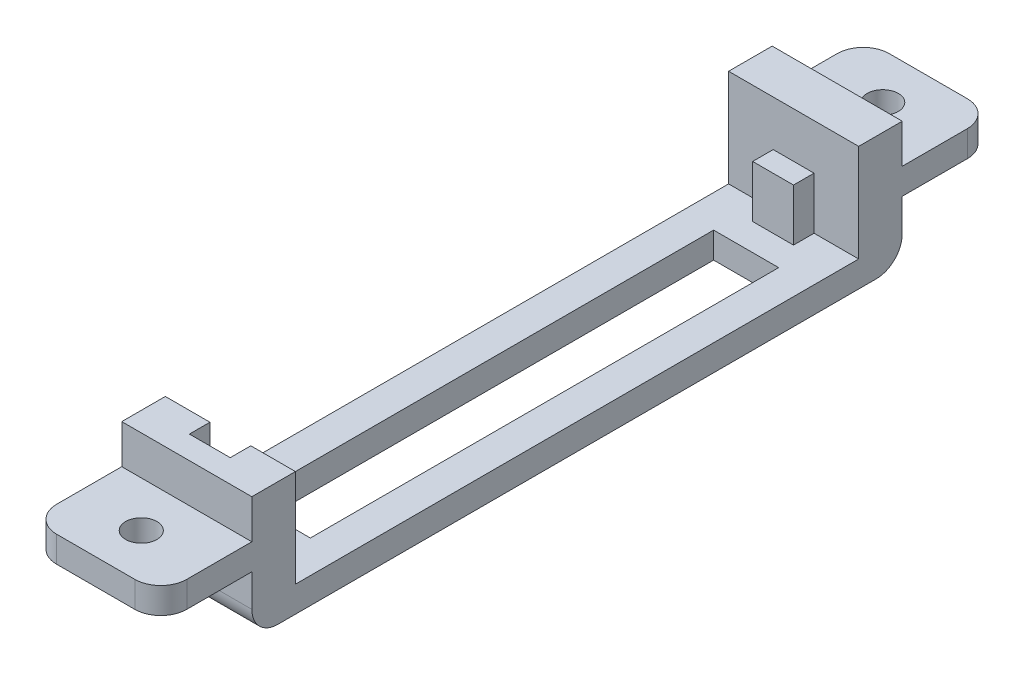
from build123d import *

# Parameters (mm, degrees)
SKETCH1_W           = 12.7
SKETCH1_H           = 63.5
SKETCH1_W_2         = 6.35
SKETCH1_H_2         = 45.72
BOSS_EXTRUDE1_DEPTH = 2.54
BOSS_EXTRUDE2_DEPTH = 9.525
SKETCH5_W           = 3.9878
SKETCH5_H           = 2.0066
CUT_EXTRUDE1_DEPTH  = 4.445
SKETCH7_W           = 12.7
SKETCH7_H           = 8.89
SKETCH7_R           = 1.524
BOSS_EXTRUDE4_DEPTH = 2.54
FILLET1_R           = 2.54


with BuildPart() as part:
    # Sketch1 → Boss-Extrude1 (new body)
    with BuildSketch(Plane(origin=(0, 0, 0), x_dir=(1, 0, 0), z_dir=(0, 1, 0))):
        Rectangle(SKETCH1_W, SKETCH1_H)
        Rectangle(SKETCH1_W_2, SKETCH1_H_2, mode=Mode.SUBTRACT)
    extrude(amount=BOSS_EXTRUDE1_DEPTH)

    # Sketch2 → Boss-Extrude2 (add)
    with BuildSketch(Plane(origin=(0, 2.54, 0), x_dir=(1, 0, 0), z_dir=(0, 1, 0))):
        Polygon((-6.35, 31.75), (6.35, 31.75), (6.35, 27.4955), (1.9939, 27.4955), (1.9939, 25.4889), (-1.9939, 25.4889), (-1.9939, 27.4955), (-6.35, 27.4955), align=None)
        Polygon((-6.35, -27.4955), (-6.35, -31.75), (6.35, -31.75), (6.35, -27.4955), (1.9939, -27.4955), (1.9939, -29.5021), (-1.9939, -29.5021), (-1.9939, -27.4955), align=None)
    extrude(amount=BOSS_EXTRUDE2_DEPTH)

    # Sketch5 → Cut-Extrude1 (cut)
    with BuildSketch(Plane(origin=(0, 12.065, 0), x_dir=(1, 0, 0), z_dir=(0, 1, 0))):
        with Locations((0, 26.4922)):
            Rectangle(SKETCH5_W, SKETCH5_H)
    extrude(amount=-CUT_EXTRUDE1_DEPTH, mode=Mode.SUBTRACT)

    # Sketch7 → Boss-Extrude4 (add)
    with BuildSketch(Plane(origin=(0, 8.255, 0), x_dir=(1, 0, 0), z_dir=(0, 1, 0))):
        with Locations((0, 36.195)):
            Rectangle(SKETCH7_W, SKETCH7_H)
        with Locations((0, 36.195)):
            Circle(SKETCH7_R, mode=Mode.SUBTRACT)
        with Locations((0, -36.195)):
            Rectangle(SKETCH7_W, SKETCH7_H)
        with Locations((0, -36.195)):
            Circle(SKETCH7_R, mode=Mode.SUBTRACT)
    extrude(amount=-BOSS_EXTRUDE4_DEPTH)

    # Fillet1
    fillet1_edges = [part.edges().sort_by_distance(p)[0] for p in [
        (6.35, 6.985, 40.64),
        (-6.35, 6.985, 40.64),
        (0, 0, 31.75),
        (0, 0, -31.75),
        (6.35, 6.985, -40.64),
        (-6.35, 6.985, -40.64),
    ]]
    fillet(fillet1_edges, radius=FILLET1_R)


solid = part.part
